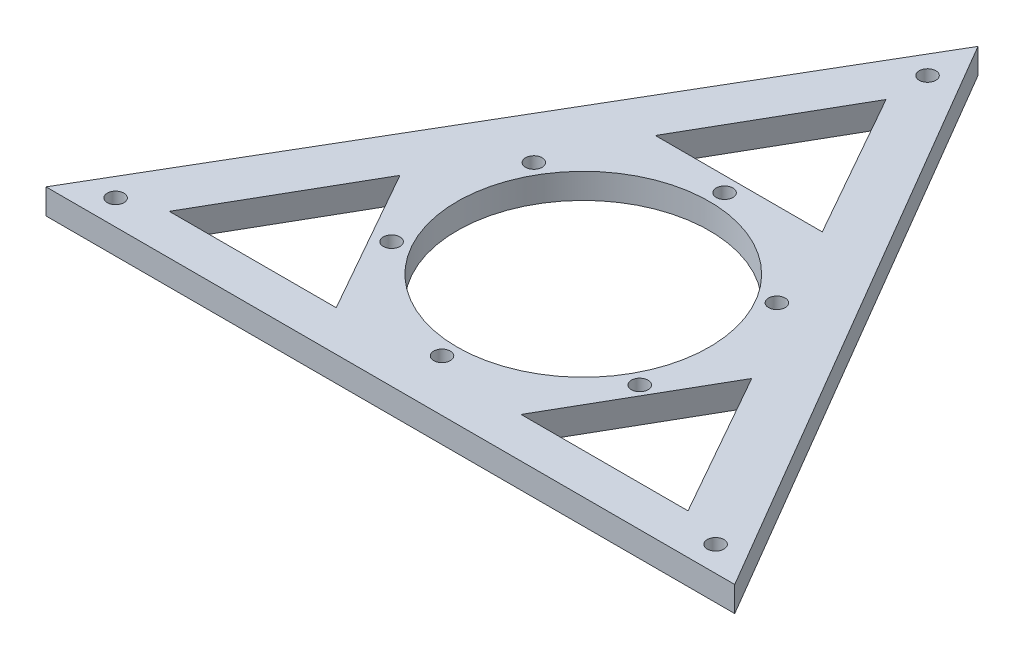
from build123d import *

# Parameters (mm, degrees)
SKETCH_1_R             = 25
EXTRUDE_1_DEPTH        = 5
HOLE_WIZARD_M4_2_D     = 3.3
HOLE_WIZARD_M4_2_DEPTH = 10.1
HOLE_WIZARD_M4_2_TIP   = 0.991420021
HOLE_WIZARD_M4_4_D     = 3.3
HOLE_WIZARD_M4_4_DEPTH = 10.1
HOLE_WIZARD_M4_4_TIP   = 0.991420021


with BuildPart() as part:
    # 草图1 → 凸台-拉伸1 (new body)
    with BuildSketch(Plane(origin=(0, 0, 0), x_dir=(1, 0, 0), z_dir=(0, 1, 0))):
        Polygon((0, 78.229669783), (-68.248539171, -38.236345737), (68.248539171, -38.236345737), align=None)
        Polygon((0, 60), (16.409255523, 30.960045876), (-16.683374686, 30.960045876), align=None, mode=Mode.SUBTRACT)
        Polygon((34.572863234, -1.184638197), (50.982118757, -30.224592321), (17.889488548, -30.224592321), align=None, mode=Mode.SUBTRACT)
        Polygon((-18.741152763, -30.224592321), (-51.833782972, -30.224592321), (-35.150408286, -1.184638197), align=None, mode=Mode.SUBTRACT)
        Circle(SKETCH_1_R, mode=Mode.SUBTRACT)
    extrude(amount=EXTRUDE_1_DEPTH)

    # M4 螺纹孔2
    with Locations(Plane(origin=(0, 5, 0), x_dir=(1, 0, 0), z_dir=(0, 1, 0))):
        with Locations((-24.082253567, 14.284434295), (0, 28), (24.082253567, 14.284434295), (24.585652853, -13.39946543), (0, -28), (-24.585652853, -13.39946543)):
            Hole(HOLE_WIZARD_M4_2_D / 2, depth=HOLE_WIZARD_M4_2_DEPTH)
            with Locations((0, 0, -(HOLE_WIZARD_M4_2_DEPTH + HOLE_WIZARD_M4_2_TIP / 2))):  # 118° drill point
                Cone(0, HOLE_WIZARD_M4_2_D / 2, HOLE_WIZARD_M4_2_TIP, mode=Mode.SUBTRACT)

    # M4 螺纹孔4
    with Locations(Plane(origin=(0, 5, 0), x_dir=(1, 0, 0), z_dir=(0, 1, 0))):
        with Locations((59.458609482, -33.236345737), (0, 68.229669783), (-59.458609482, -33.236345737)):
            Hole(HOLE_WIZARD_M4_4_D / 2, depth=HOLE_WIZARD_M4_4_DEPTH)
            with Locations((0, 0, -(HOLE_WIZARD_M4_4_DEPTH + HOLE_WIZARD_M4_4_TIP / 2))):  # 118° drill point
                Cone(0, HOLE_WIZARD_M4_4_D / 2, HOLE_WIZARD_M4_4_TIP, mode=Mode.SUBTRACT)


solid = part.part
